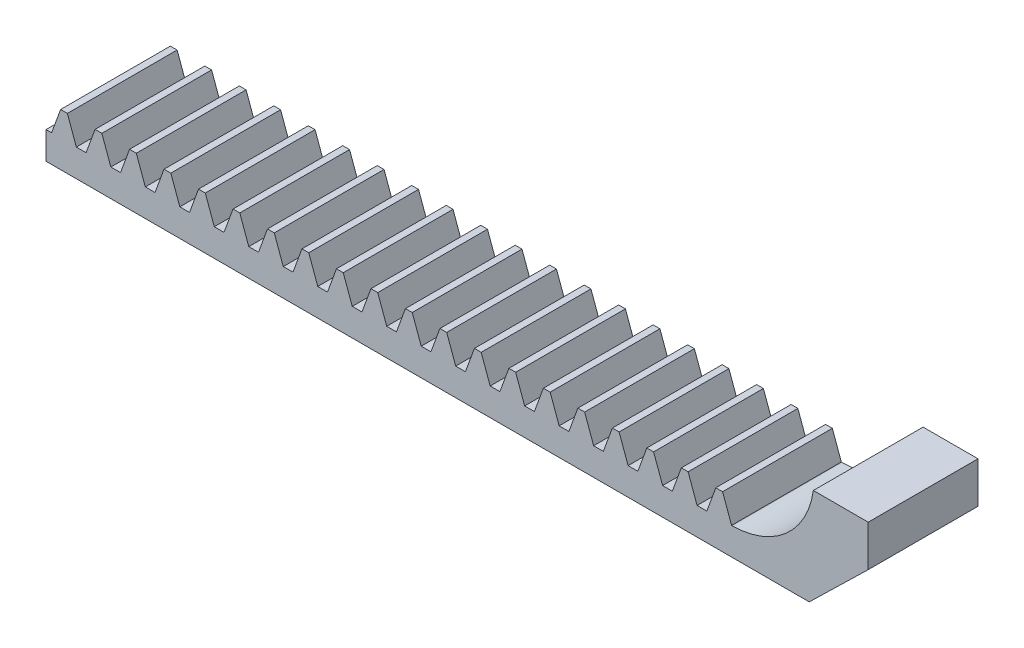
from build123d import *

# Parameters (mm, degrees)
BLANKSKE_W          = 60
BLANKSKE_H          = 3.8
BLANK_DEPTH         = 8
TOOTHCUTSIM_DEPTH   = 61.65014427
TEETHCUTS_COUNT     = 25
TEETHCUTS_PITCH     = 2.51327412
EXTRUDE_1_DEPTH     = 8
SKETCH_2_W          = 10
SKETCH_2_H          = 6.666959913
CUT_EXTRUDE_1_DEPTH = 8


with BuildPart() as part:
    # BlankSke → Blank (new body)
    with BuildSketch(Plane.XY):
        with Locations((30, 1.9)):
            Rectangle(BLANKSKE_W, BLANKSKE_H)
    extrude(amount=-BLANK_DEPTH)

    # TooCutSkeSim → ToothCutSim (cut, through all)
    with BuildSketch(Plane.XY):
        Polygon((0.354348296, 2), (-0.354348296, 2), (-1.018739561, 3.8254), (1.018739561, 3.8254), align=None)
    toothcutsim = extrude(amount=-TOOTHCUTSIM_DEPTH, mode=Mode.SUBTRACT)

    # TeethCuts: ToothCutSim ×25
    with Locations(*[(i * TEETHCUTS_PITCH, 0, 0) for i in range(1, TEETHCUTS_COUNT)]):
        add(toothcutsim, mode=Mode.SUBTRACT)

    # 草图1 → 凸台-拉伸1 (add)
    with BuildSketch(Plane.XY):
        with BuildLine():
            Line((60, 0), (65.623907225, 0))
            Line((65.623907225, 0), (69.923907225, 4.183835629))
            Line((69.923907225, 4.183835629), (69.923907225, 7.183835629))
            Line((69.923907225, 7.183835629), (65.923907225, 7.183835629))
            ThreePointArc((65.923907225, 7.183835629), (63.930879619, 3.484662843), (60, 2))
            Line((60, 2), (60, 0))
        make_face()
    extrude(amount=-EXTRUDE_1_DEPTH)

    # 草图2 → 切除-拉伸1 (cut)
    with BuildSketch(Plane.XY):
        with Locations((5, 3.333479957)):
            Rectangle(SKETCH_2_W, SKETCH_2_H)
    extrude(amount=-CUT_EXTRUDE_1_DEPTH, mode=Mode.SUBTRACT)


solid = part.part
